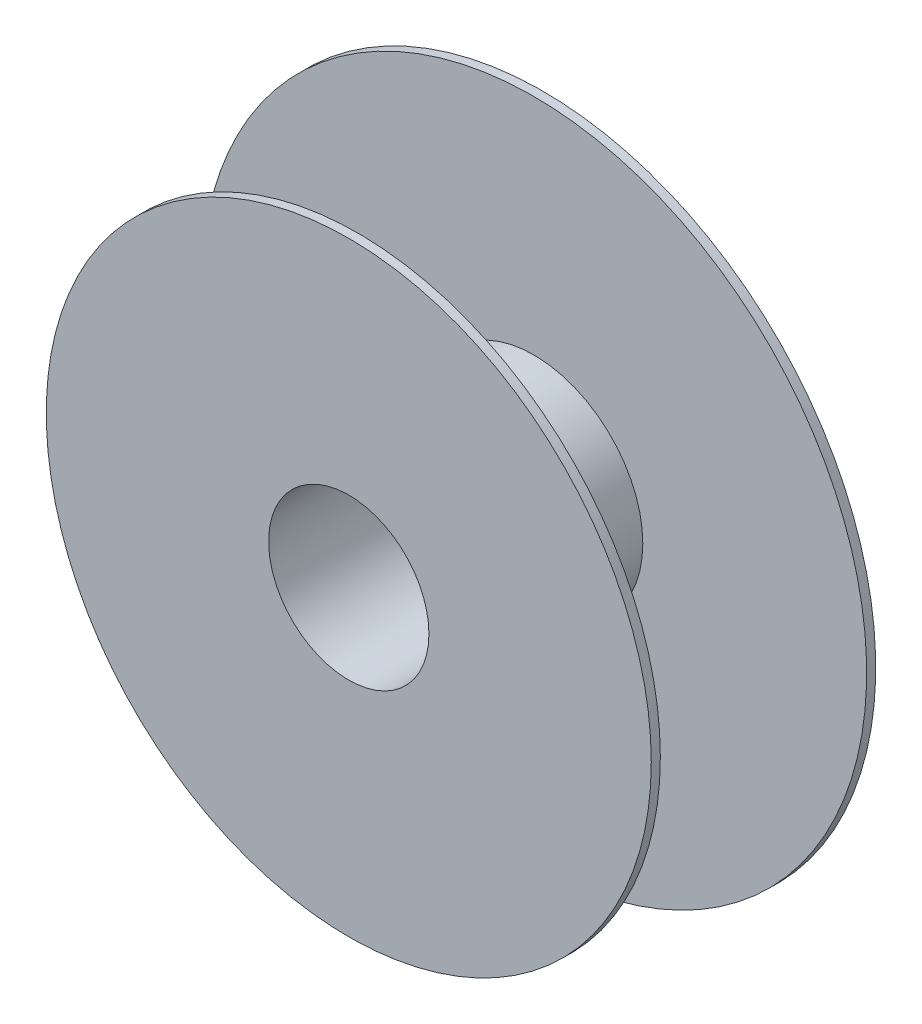
from build123d import *

# Parameters (mm, degrees)
EXTRUDE1_DEPTH      = 29.1
EXTRUDE1_DEPTH_BACK = 29.1
SKETCH1_R           = 36
SKETCH1_R_2         = 26.5
SKETCH2_R           = 100
SKETCH2_R_2         = 26.5
EXTRUDE4_DEPTH      = 3
EXTRUDE5_START      = 3
SKETCH4_R           = 110
SKETCH4_R_2         = 26.5
EXTRUDE5_DEPTH      = 3


with BuildPart() as part:
    # Sketch1 → Extrude1 (new, two sides: drawn at the far end of the back side and taken through both)
    with BuildSketch(Plane.XY.offset(-EXTRUDE1_DEPTH_BACK)):
        Circle(SKETCH1_R)
        Circle(SKETCH1_R_2, mode=Mode.SUBTRACT)
    extrude(amount=EXTRUDE1_DEPTH + EXTRUDE1_DEPTH_BACK)

    # Sketch2 → Extrude4 (add)
    with BuildSketch(Plane.XY.offset(29.1)):
        Circle(SKETCH2_R)
        Circle(SKETCH2_R_2, mode=Mode.SUBTRACT)
    extrude(amount=EXTRUDE4_DEPTH)

    # Sketch4 → Extrude5 (add)
    with BuildSketch(Plane(origin=(0, 0, -29.1), x_dir=(-1, 0, 0), z_dir=(0, 0, -1)).offset(EXTRUDE5_START)):
        Circle(SKETCH4_R)
        Circle(SKETCH4_R_2, mode=Mode.SUBTRACT)
    extrude(amount=-EXTRUDE5_DEPTH)


solid = part.part
